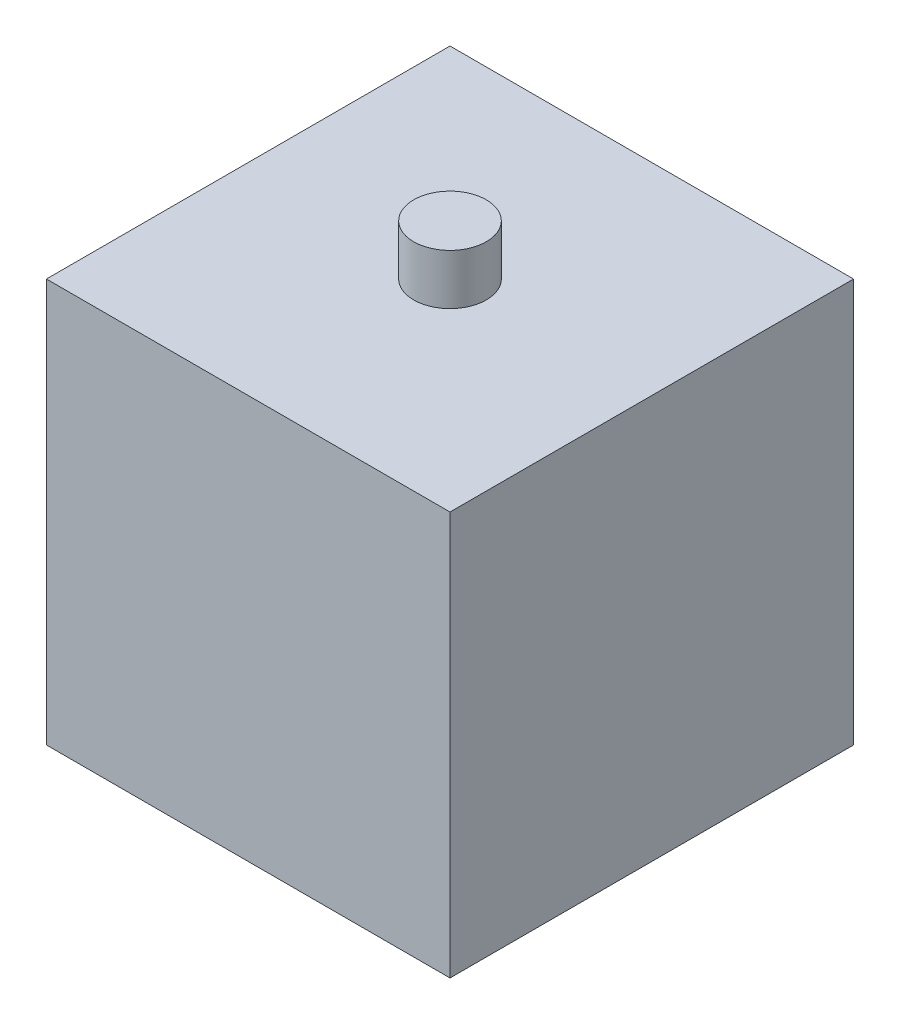
from build123d import *

# Parameters (mm, degrees)
SKETCH1_W           = 25.4
SKETCH1_H           = 25.4
BOSS_EXTRUDE1_DEPTH = 12.7
SKETCH2_R           = 2.286
BOSS_EXTRUDE2_DEPTH = 3.175


with BuildPart() as part:
    # Sketch1 → Boss-Extrude1 (new body, symmetric)
    with BuildSketch(Plane(origin=(0, 0, 0), x_dir=(1, 0, 0), z_dir=(0, 1, 0))):
        Rectangle(SKETCH1_W, SKETCH1_H)
    extrude(amount=BOSS_EXTRUDE1_DEPTH, both=True)

    # Sketch2 → Boss-Extrude2 (add)
    with BuildSketch(Plane(origin=(0, 12.7, 0), x_dir=(1, 0, 0), z_dir=(0, 1, 0))):
        Circle(SKETCH2_R)
    extrude(amount=BOSS_EXTRUDE2_DEPTH)


solid = part.part
